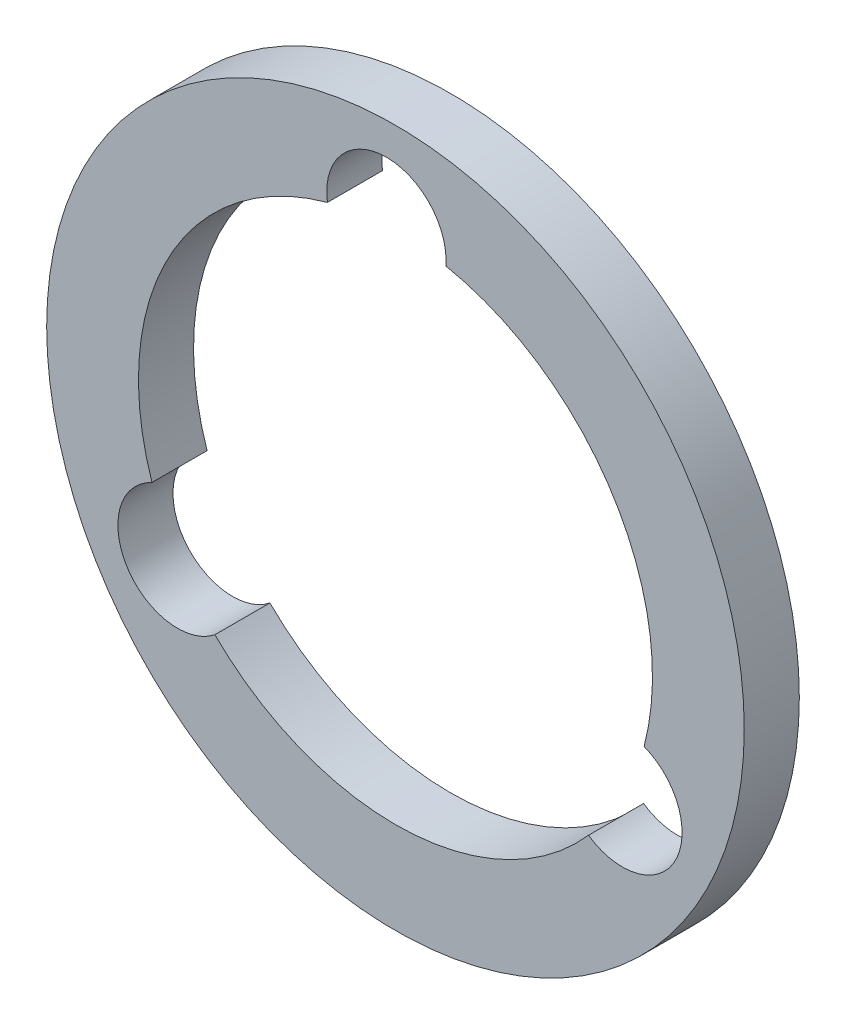
from build123d import *

# Parameters (mm, degrees)
ESQUISSE1_R        = 19
BOSS_EXTRU_2_DEPTH = 3


with BuildPart() as part:
    # Esquisse1 → Boss.-Extru.2 (new body)
    with BuildSketch(Plane.XY):
        Circle(ESQUISSE1_R)
        with BuildLine():
            ThreePointArc((2.745524809, 13.728149676), (-0.608438359, 17.239266306), (-3.706523595, 13.500432691))
            ThreePointArc((-3.706523595, 13.500432691), (-12.363713879, 6.567996584), (-13.261688771, -4.486380606))
            ThreePointArc((-13.261688771, -4.486380606), (-14.625423384, -9.146556229), (-9.838455875, -9.960159939))
            ThreePointArc((-9.838455875, -9.960159939), (0.493805045, -13.991288596), (10.516163961, -9.24176907))
            ThreePointArc((10.516163961, -9.24176907), (15.233861743, -8.092710077), (13.54497947, -3.540272752))
            ThreePointArc((13.54497947, -3.540272752), (11.869908833, 7.423292012), (2.745524809, 13.728149676))
        make_face(mode=Mode.SUBTRACT)
    extrude(amount=BOSS_EXTRU_2_DEPTH)


solid = part.part
